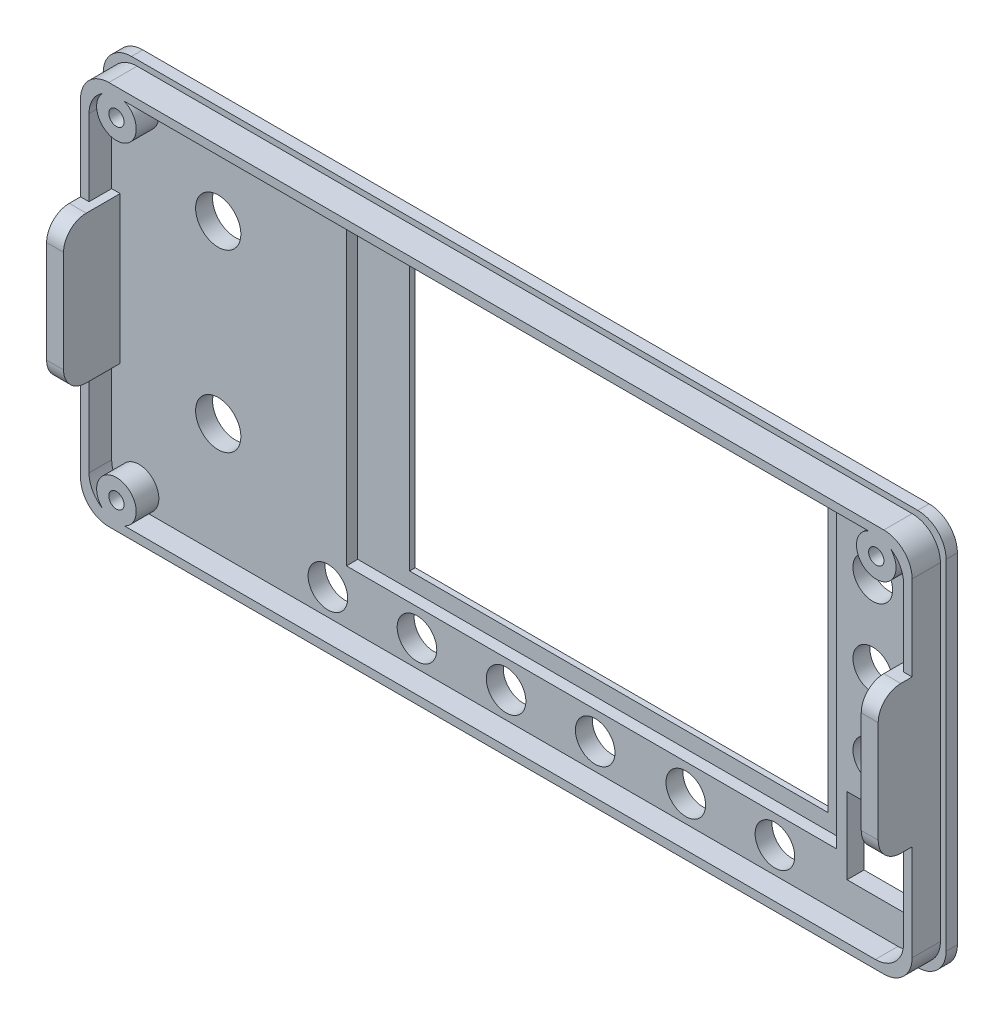
from build123d import *

# Parameters (mm, degrees)
SKETCH_1_W           = 149
SKETCH_1_H           = 70
EXTRUDE_1_DEPTH      = 1
SKETCH_2_W           = 147
SKETCH_2_H           = 68
EXTRUDE_2_DEPTH      = 2
FILLET_1_R           = 5
SKETCH_3_W           = 3
SKETCH_3_H           = 26
EXTRUDE_3_DEPTH      = 10
FILLET_2_R           = 4
SKETCH_6_R           = 3.5
EXTRUDE_4_DEPTH      = 4
SKETCH_7_W           = 86.66
SKETCH_7_H           = 55.5
CUT_EXTRUDE_3_DEPTH  = 2
SKETCH_8_W           = 74
SKETCH_8_H           = 49
CUT_EXTRUDE_4_DEPTH  = 2
SKETCH_11_R          = 4
CUT_EXTRUDE_7_DEPTH  = 4
SKETCH_12_R          = 1.35
CUT_EXTRUDE_8_DEPTH  = 4
SKETCH_13_R          = 1.35
CUT_EXTRUDE_9_DEPTH  = 4
SKETCH_14_R          = 1.35
CUT_EXTRUDE_10_DEPTH = 4
SKETCH_15_W          = 14
SKETCH_15_H          = 13.5
CUT_EXTRUDE_11_DEPTH = 4
SKETCH_9_R           = 3.5
CUT_EXTRUDE_12_DEPTH = 4
SKETCH_16_R          = 3.5
CUT_EXTRUDE_13_DEPTH = 4
EXTRUDE_5_DEPTH      = 4
EXTRUDE_6_DEPTH      = 1


with BuildPart() as part:
    # Эскиз1 → Бобышка-Вытянуть1 (new body)
    with BuildSketch(Plane.XY):
        Rectangle(SKETCH_1_W, SKETCH_1_H)
    extrude(amount=EXTRUDE_1_DEPTH)

    # Эскиз2 → Бобышка-Вытянуть2 (add)
    with BuildSketch(Plane.XY.offset(1)):
        Rectangle(SKETCH_2_W, SKETCH_2_H)
    extrude(amount=EXTRUDE_2_DEPTH)

    # Скругление1
    fillet_1_edges = [part.edges().sort_by_distance(p)[0] for p in [
        (-73.5, 34, 2),
        (-73.5, -34, 2),
        (73.5, -34, 2),
        (73.5, 34, 2),
        (-74.5, 35, 0.5),
        (74.5, 35, 0.5),
        (74.5, -35, 0.5),
        (-74.5, -35, 0.5),
    ]]
    fillet(fillet_1_edges, radius=FILLET_1_R)

    # Эскиз3 → Бобышка-Вытянуть3 (add)
    with BuildSketch(Plane.XY.offset(3)):
        with Locations((-72, 1)):
            Rectangle(SKETCH_3_W, SKETCH_3_H)
        with Locations((72, 1)):
            Rectangle(SKETCH_3_W, SKETCH_3_H)
    extrude(amount=EXTRUDE_3_DEPTH)

    # Скругление2
    fillet_2_edges = [part.edges().sort_by_distance(p)[0] for p in [
        (-72, -12, 13),
        (-72, 14, 13),
        (72, 14, 13),
        (72, -12, 13),
    ]]
    fillet(fillet_2_edges, radius=FILLET_2_R)

    # Эскиз6 → Бобышка-Вытянуть4 (add)
    with BuildSketch(Plane.XY.offset(3)):
        with Locations((-67.16, 29.285)):
            Circle(SKETCH_6_R)
        with Locations((67.16, 29.285)):
            Circle(SKETCH_6_R)
        with Locations((-67.16, -29.285)):
            Circle(SKETCH_6_R)
    extrude(amount=EXTRUDE_4_DEPTH)

    # Эскиз7 → Вырез-Вытянуть3 (cut)
    with BuildSketch(Plane.XY.offset(3)):
        with Locations((12.83, 4.75)):
            Rectangle(SKETCH_7_W, SKETCH_7_H)
    extrude(amount=-CUT_EXTRUDE_3_DEPTH, mode=Mode.SUBTRACT)

    # Эскиз8 → Вырез-Вытянуть4 (cut, through all)
    with BuildSketch(Plane.XY.offset(1)):
        with Locations((15.66, 4.3)):
            Rectangle(SKETCH_8_W, SKETCH_8_H)
    extrude(amount=-CUT_EXTRUDE_4_DEPTH, mode=Mode.SUBTRACT)

    # Эскиз11 → Вырез-Вытянуть7 (cut, through all)
    with BuildSketch(Plane.XY.offset(3)):
        with Locations((-53.163, 18.448)):
            Circle(SKETCH_11_R)
        with Locations((-53.163, -12.552)):
            Circle(SKETCH_11_R)
    extrude(amount=-CUT_EXTRUDE_7_DEPTH, mode=Mode.SUBTRACT)

    # Эскиз12 → Вырез-Вытянуть8 (cut)
    with BuildSketch(Plane.XY.offset(7)):
        with Locations((-67.16, 29.285)):
            Circle(SKETCH_12_R)
    extrude(amount=-CUT_EXTRUDE_8_DEPTH, mode=Mode.SUBTRACT)

    # Эскиз13 → Вырез-Вытянуть9 (cut)
    with BuildSketch(Plane.XY.offset(7)):
        with Locations((67.16, 29.285)):
            Circle(SKETCH_13_R)
    extrude(amount=-CUT_EXTRUDE_9_DEPTH, mode=Mode.SUBTRACT)

    # Эскиз14 → Вырез-Вытянуть10 (cut)
    with BuildSketch(Plane.XY.offset(7)):
        with Locations((-67.16, -29.285)):
            Circle(SKETCH_14_R)
    extrude(amount=-CUT_EXTRUDE_10_DEPTH, mode=Mode.SUBTRACT)

    # Эскиз15 → Вырез-Вытянуть11 (cut, through all)
    with BuildSketch(Plane.XY.offset(3)):
        with Locations((65, -20.05)):
            Rectangle(SKETCH_15_W, SKETCH_15_H)
    extrude(amount=-CUT_EXTRUDE_11_DEPTH, mode=Mode.SUBTRACT)

    # Эскиз9 → Вырез-Вытянуть12 (cut, through all)
    with BuildSketch(Plane.XY.offset(3)):
        with Locations((62.54, -6.405)):
            Circle(SKETCH_9_R)
        with Locations((62.54, 21.595)):
            Circle(SKETCH_9_R)
        with Locations((62.54, 7.595)):
            Circle(SKETCH_9_R)
    extrude(amount=-CUT_EXTRUDE_12_DEPTH, mode=Mode.SUBTRACT)

    # Эскиз16 → Вырез-Вытянуть13 (cut, through all)
    with BuildSketch(Plane.XY.offset(3)):
        with Locations((45.24, -27.88)):
            Circle(SKETCH_16_R)
        with Locations((29.49, -27.88)):
            Circle(SKETCH_16_R)
        with Locations((13.47, -27.88)):
            Circle(SKETCH_16_R)
        with Locations((-2.28, -27.88)):
            Circle(SKETCH_16_R)
        with Locations((-18.03, -27.88)):
            Circle(SKETCH_16_R)
        with Locations((-33.78, -27.88)):
            Circle(SKETCH_16_R)
    extrude(amount=-CUT_EXTRUDE_13_DEPTH, mode=Mode.SUBTRACT)

    # Эскиз17 → Бобышка-Вытянуть5 (add)
    with BuildSketch(Plane.XY.offset(3)):
        with BuildLine():
            Line((68.5, -34), (-68.5, -34))
            ThreePointArc((-68.5, -34), (-72.035533906, -32.535533906), (-73.5, -29))
            Line((-73.5, -29), (-73.5, 29))
            ThreePointArc((-73.5, 29), (-72.035533906, 32.535533906), (-68.5, 34))
            Line((-68.5, 34), (68.5, 34))
            ThreePointArc((68.5, 34), (72.035533906, 32.535533906), (73.5, 29))
            Line((73.5, 29), (73.5, -29))
            ThreePointArc((73.5, -29), (72.035533906, -32.535533906), (68.5, -34))
        make_face()
        with BuildLine():
            Line((67, -32.5), (-67, -32.5))
            ThreePointArc((-67, -32.5), (-70.535533906, -31.035533906), (-72, -27.5))
            Line((-72, -27.5), (-72, 27.5))
            ThreePointArc((-72, 27.5), (-70.535533906, 31.035533906), (-67, 32.5))
            Line((-67, 32.5), (67, 32.5))
            ThreePointArc((67, 32.5), (70.535533906, 31.035533906), (72, 27.5))
            Line((72, 27.5), (72, -27.5))
            ThreePointArc((72, -27.5), (70.535533906, -31.035533906), (67, -32.5))
        make_face(mode=Mode.SUBTRACT)
    extrude(amount=EXTRUDE_5_DEPTH)

    # Эскиз18 → Бобышка-Вытянуть6 (add)
    with BuildSketch(Plane.XY.offset(1)):
        with BuildLine():
            Line((69.5, -35), (-69.5, -35))
            ThreePointArc((-69.5, -35), (-73.035533906, -33.535533906), (-74.5, -30))
            Line((-74.5, -30), (-74.5, 30))
            ThreePointArc((-74.5, 30), (-73.035533906, 33.535533906), (-69.5, 35))
            Line((-69.5, 35), (69.5, 35))
            ThreePointArc((69.5, 35), (73.035533906, 33.535533906), (74.5, 30))
            Line((74.5, 30), (74.5, -30))
            ThreePointArc((74.5, -30), (73.035533906, -33.535533906), (69.5, -35))
        make_face()
        with BuildLine():
            Line((68.5, -34), (-68.5, -34))
            ThreePointArc((-68.5, -34), (-72.035533906, -32.535533906), (-73.5, -29))
            Line((-73.5, -29), (-73.5, 29))
            ThreePointArc((-73.5, 29), (-72.035533906, 32.535533906), (-68.5, 34))
            Line((-68.5, 34), (68.5, 34))
            ThreePointArc((68.5, 34), (72.035533906, 32.535533906), (73.5, 29))
            Line((73.5, 29), (73.5, -29))
            ThreePointArc((73.5, -29), (72.035533906, -32.535533906), (68.5, -34))
        make_face(mode=Mode.SUBTRACT)
    extrude(amount=EXTRUDE_6_DEPTH)


solid = part.part
